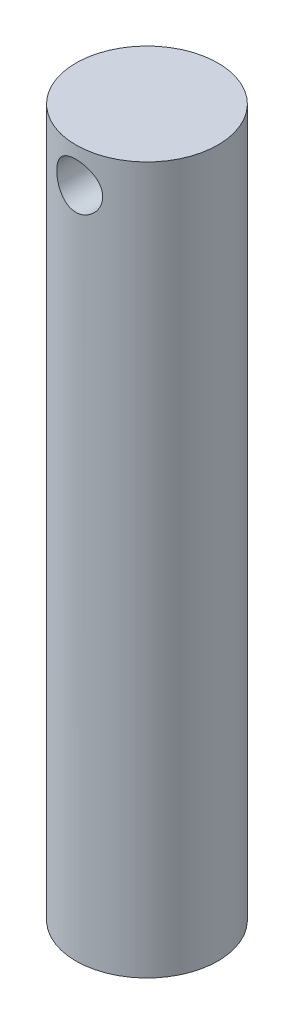
from build123d import *

# Parameters (mm, degrees)
SKETCH1_R               = 10.05
BOSS_EXTRUDE1_DEPTH     = 100
SKETCH2_R               = 3.25
CUT_EXTRUDE1_DEPTH      = 11.05
CUT_EXTRUDE1_DEPTH_BACK = 11.05


with BuildPart() as part:
    # Sketch1 → Boss-Extrude1 (new body)
    with BuildSketch(Plane(origin=(0, 0, 0), x_dir=(1, 0, 0), z_dir=(0, 1, 0))):
        Circle(SKETCH1_R)
    extrude(amount=BOSS_EXTRUDE1_DEPTH)

    # Sketch2 → Cut-Extrude1 (cut, two sides)
    with BuildSketch(Plane.XY) as cut_extrude1_sk:
        with Locations((0, 95)):
            Circle(SKETCH2_R)
    extrude(amount=CUT_EXTRUDE1_DEPTH, mode=Mode.SUBTRACT)
    extrude(cut_extrude1_sk.sketch, amount=-CUT_EXTRUDE1_DEPTH_BACK, mode=Mode.SUBTRACT)


solid = part.part
